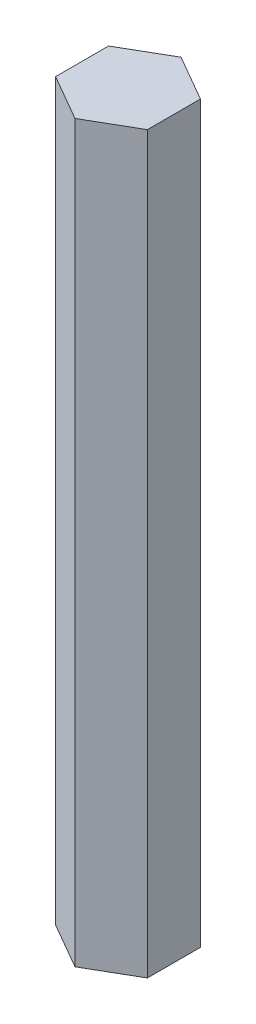
from build123d import *

# Parameters (mm, degrees)
BOSS_EXTRUDE1_DEPTH = 80
SKETCH2_R           = 3
CUT_EXTRUDE1_DEPTH  = 5


with BuildPart() as part:
    # Sketch1 → Boss-Extrude1 (new body)
    with BuildSketch(Plane(origin=(0, 0, 0), x_dir=(1, 0, 0), z_dir=(0, 1, 0))):
        Polygon((0, 5.773502692), (-5, 2.886751346), (-5, -2.886751346), (0, -5.773502692), (5, -2.886751346), (5, 2.886751346), align=None)
    extrude(amount=BOSS_EXTRUDE1_DEPTH)

    # Sketch2 → Cut-Extrude1 (cut)
    with BuildSketch(Plane.XZ):
        Circle(SKETCH2_R)
    extrude(amount=-CUT_EXTRUDE1_DEPTH, mode=Mode.SUBTRACT)


solid = part.part
